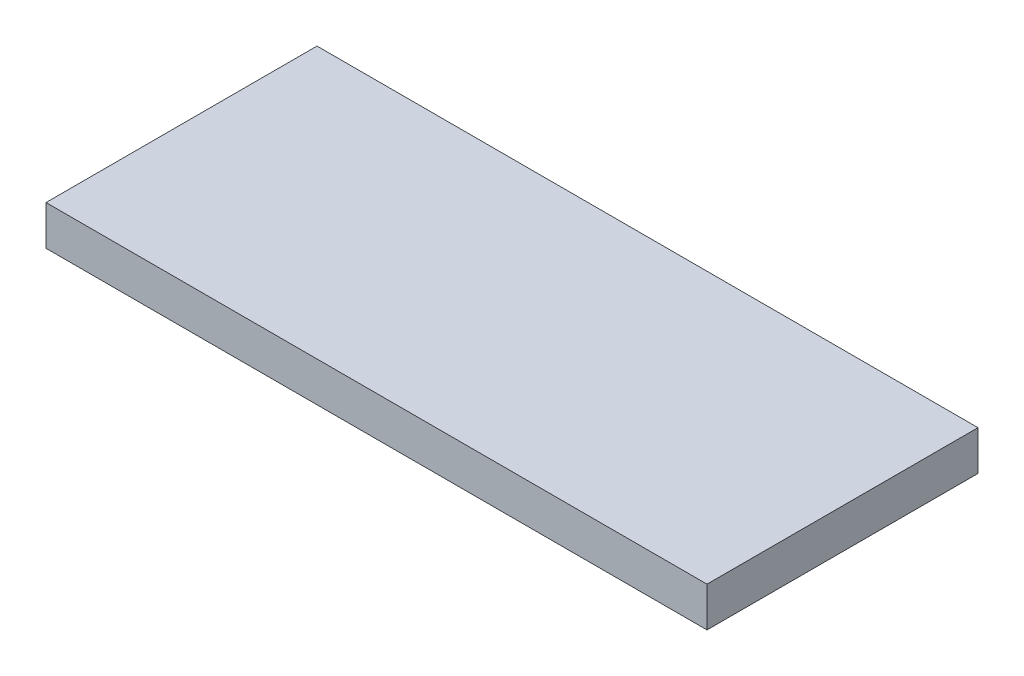
from build123d import *

# Parameters (mm, degrees)
ESQUISSE1_W        = 100
ESQUISSE1_H        = 41
BOSS_EXTRU_1_DEPTH = 6


with BuildPart() as part:
    # Esquisse1 → Boss.-Extru.1 (new body)
    with BuildSketch(Plane(origin=(0, 0, 0), x_dir=(1, 0, 0), z_dir=(0, 1, 0))):
        with Locations((13.714285714, 1.714285714)):
            Rectangle(ESQUISSE1_W, ESQUISSE1_H)
    extrude(amount=BOSS_EXTRU_1_DEPTH)


solid = part.part
